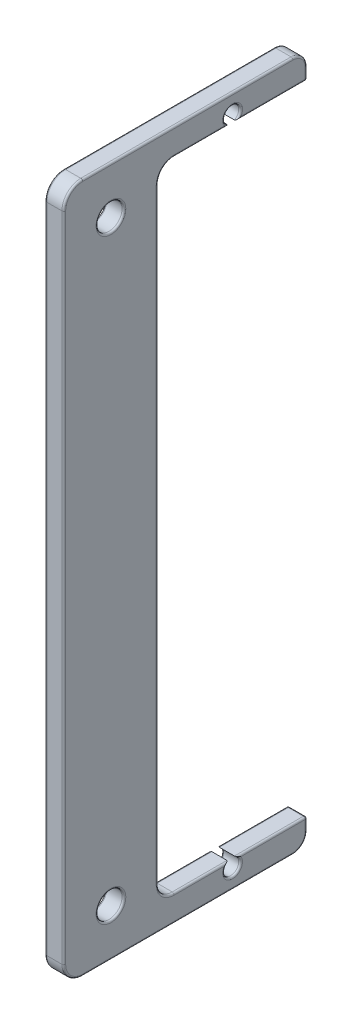
from build123d import *

# Parameters (mm, degrees)
BOSS_EXTRUDE1_DEPTH = 4
SKETCH6_R           = 1.7
SKETCH6_R_2         = 2.75
HOLES_DEPTH         = 5
FILLET1_R           = 0.4
FILLET3_R           = 3
FILLET5_R           = 4
FILLET6_R           = 3.4
FILLET7_R           = 0.4


with BuildPart() as part:
    # Sketch1 → Boss-Extrude1 (new body)
    with BuildSketch(Plane(origin=(102.034991665, 0, 0), x_dir=(0, -1, 0), z_dir=(-1, 0, 0))):
        Polygon((-127.6, 102.478290724), (7.6, 102.478290724), (7.6, 70.878290724), (13.2, 70.878290724), (13.2, 122.478290724), (-133.2, 122.478290724), (-133.2, 70.878290724), (-127.6, 70.878290724), align=None)
    extrude(amount=-BOSS_EXTRUDE1_DEPTH)

    # Sketch6 → Holes (cut, through all)
    with BuildSketch(Plane(origin=(106.034991665, 0, 0), x_dir=(0, 0, -1), z_dir=(1, 0, 0))):
        with Locations((-86.678290724, 129.1)):
            Circle(SKETCH6_R)
        with Locations((-112.478290724, 123.2)):
            Circle(SKETCH6_R_2)
        with Locations((-112.478290724, -3.2)):
            Circle(SKETCH6_R_2)
        with Locations((-86.678290724, -9.1)):
            Circle(SKETCH6_R)
    extrude(amount=-HOLES_DEPTH, mode=Mode.SUBTRACT)

    # Fillet1
    fillet1_edges = [part.edges().sort_by_distance(p)[0] for p in [
        (104.034991665, 127.6, 70.878290724),
        (104.034991665, -7.6, 70.878290724),
        (102.034991665, 123.2, 115.228290724),
        (106.034991665, 123.2, 115.228290724),
        (102.034991665, -3.2, 115.228290724),
        (106.034991665, -3.2, 115.228290724),
    ]]
    fillet(fillet1_edges, radius=FILLET1_R)

    # Fillet3
    fillet3_edges = [part.edges().sort_by_distance(p)[0] for p in [
        (104.034991665, 133.2, 70.878290724),
        (104.034991665, -13.2, 70.878290724),
    ]]
    fillet(fillet3_edges, radius=FILLET3_R)

    # Fillet5
    fillet5_edges = [part.edges().sort_by_distance(p)[0] for p in [
        (104.034991665, 133.2, 122.478290724),
        (104.034991665, -13.2, 122.478290724),
    ]]
    fillet(fillet5_edges, radius=FILLET5_R)

    # Fillet6
    fillet6_edges = [part.edges().sort_by_distance(p)[0] for p in [
        (104.034991665, -7.6, 102.478290724),
        (104.034991665, 127.6, 102.478290724),
    ]]
    fillet(fillet6_edges, radius=FILLET6_R)

    # Fillet7
    fillet7_edges = [part.edges().sort_by_distance(p)[0] for p in [
        (102.034991665, 60, 102.478290724),
        (106.034991665, 60, 102.478290724),
        (102.034991665, -7.6, 93.278290724),
        (106.034991665, -7.6, 93.278290724),
        (102.034991665, -6.604163056, 101.48245378),
        (106.034991665, -6.604163056, 101.48245378),
        (102.034991665, 126.604163056, 101.48245378),
        (106.034991665, 126.604163056, 101.48245378),
        (102.034991665, 127.6, 93.278290724),
        (102.034991665, -7.6, 78.578290724),
        (102.034991665, -10.8, 86.678290724),
        (102.034991665, 130.8, 86.678290724),
        (106.034991665, 127.6, 93.278290724),
        (106.034991665, -7.6, 78.578290724),
        (106.034991665, 130.8, 86.678290724),
        (106.034991665, -10.8, 86.678290724),
        (102.034991665, 127.6, 78.578290724),
        (102.034991665, -9.1, 70.878290724),
        (102.034991665, 127.717157288, 70.995448012),
        (102.034991665, -7.717157288, 70.995448012),
        (106.034991665, 127.6, 78.578290724),
        (106.034991665, -9.1, 70.878290724),
        (106.034991665, 127.717157288, 70.995448012),
        (106.034991665, -7.717157288, 70.995448012),
        (102.034991665, -13.2, 96.178290724),
        (102.034991665, 129.1, 70.878290724),
        (102.034991665, 132.321320344, 71.756970381),
        (102.034991665, -12.321320344, 71.756970381),
        (106.034991665, -13.2, 96.178290724),
        (106.034991665, 129.1, 70.878290724),
        (106.034991665, 132.321320344, 71.756970381),
        (106.034991665, -12.321320344, 71.756970381),
        (102.034991665, 60, 122.478290724),
        (106.034991665, 60, 122.478290724),
        (102.034991665, 133.2, 96.178290724),
        (102.034991665, -12.028427125, 121.306717849),
        (102.034991665, 132.028427125, 121.306717849),
        (106.034991665, 133.2, 96.178290724),
        (106.034991665, -12.028427125, 121.306717849),
        (106.034991665, 132.028427125, 121.306717849),
    ]]
    fillet(fillet7_edges, radius=FILLET7_R)


solid = part.part
